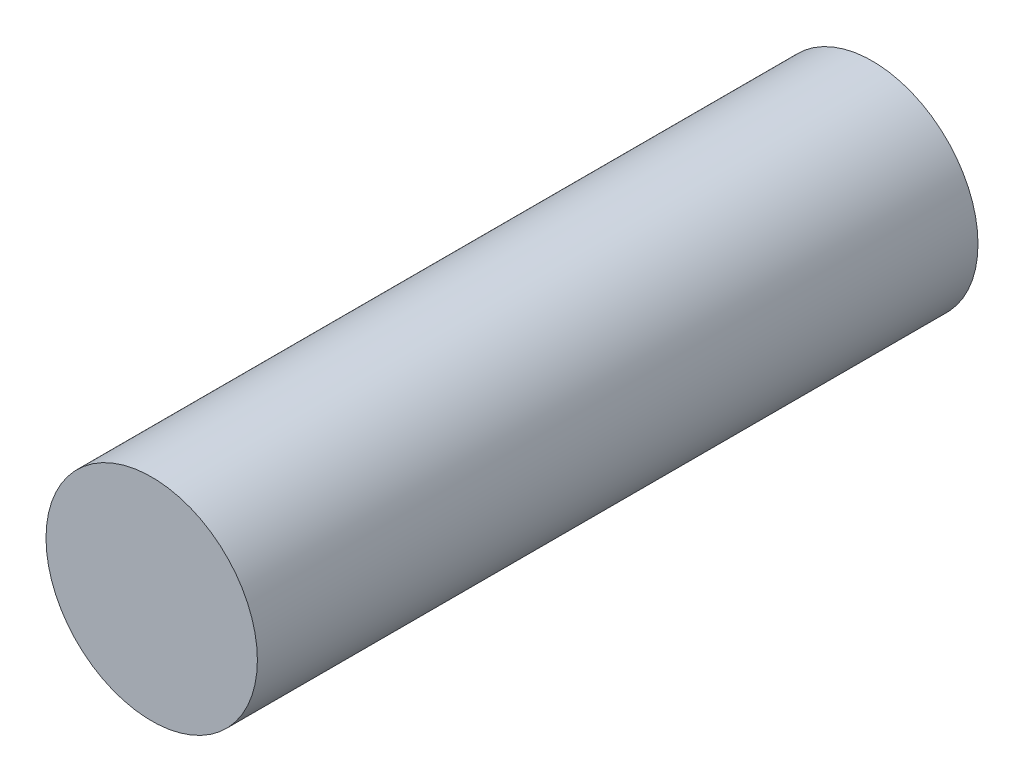
from build123d import *

# Parameters (mm, degrees)
SKETCH_1_R      = 2.2
EXTRUDE_1_DEPTH = 15


with BuildPart() as part:
    # Эскиз1 → Бобышка-Вытянуть1 (new body)
    with BuildSketch(Plane.XY):
        Circle(SKETCH_1_R)
    extrude(amount=EXTRUDE_1_DEPTH)


solid = part.part
